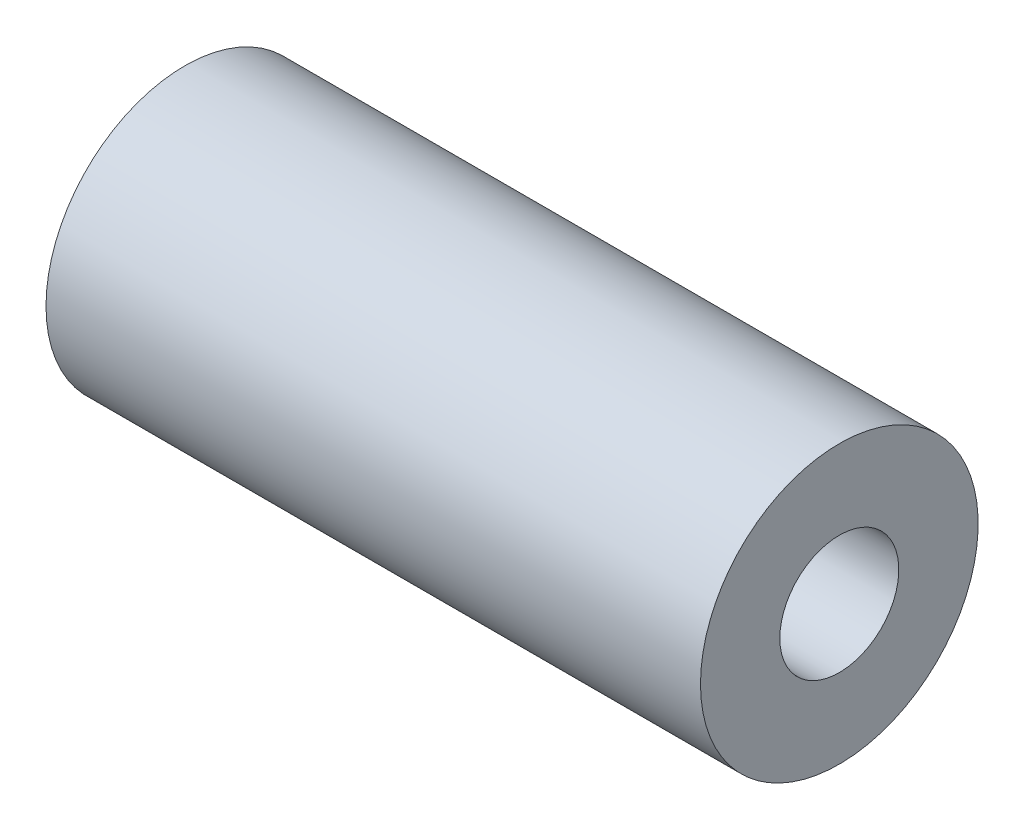
from build123d import *

# Parameters (mm, degrees)
SKETCH1_W = 33
SKETCH1_H = 4


with BuildPart() as part:
    # Sketch1 → Revolve1 (revolve)
    with BuildSketch(Plane.XY):
        with Locations((0, 5)):
            Rectangle(SKETCH1_W, SKETCH1_H)
    revolve(axis=Axis((-37.003163219, 0, 0), (1, 0, 0)))


solid = part.part
